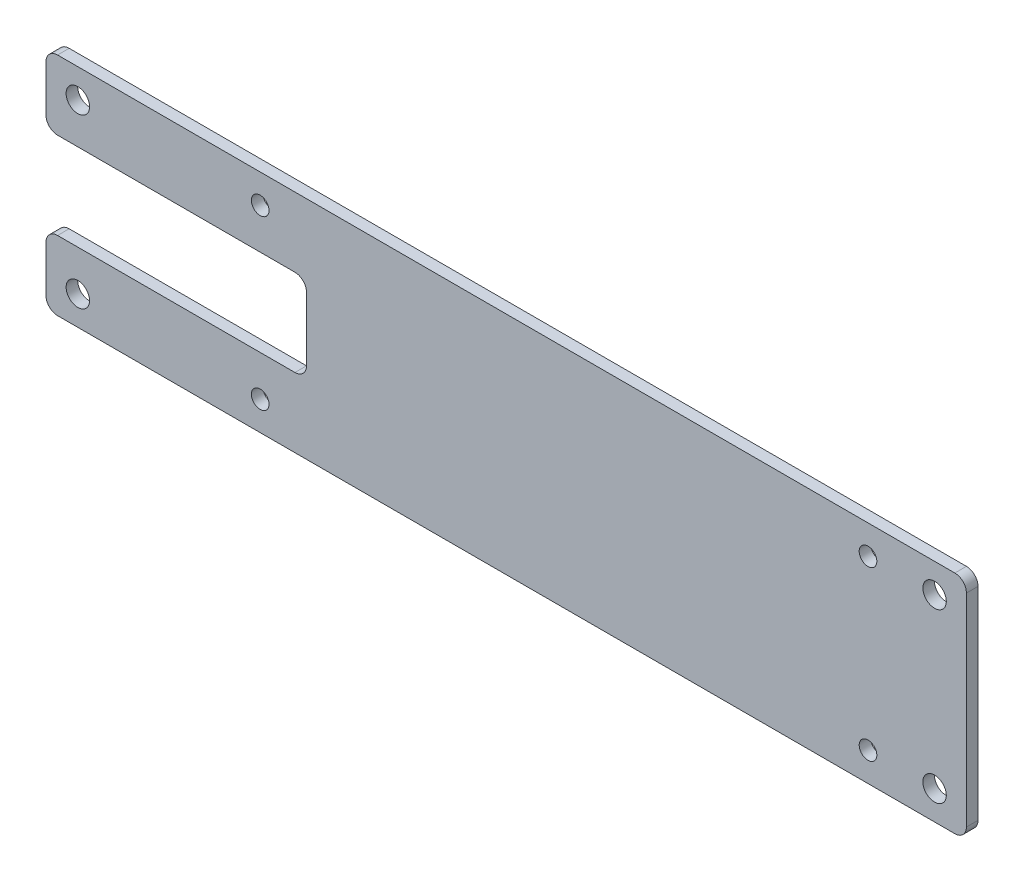
from build123d import *

# Parameters (mm, degrees)
SKETCH_1_W          = 32
SKETCH_1_H          = 39
SKETCH_1_R          = 2.025
SKETCH_1_W_2        = 115
SKETCH_1_R_2        = 1.525
SKETCH_1_W_3        = 12
EXTRUDE_1_DEPTH     = 2
SKETCH_2_W          = 19
SKETCH_2_H          = 15
SKETCH_2_W_2        = 26
CUT_EXTRUDE_1_DEPTH = 10
FILLET_1_R          = 2


with BuildPart() as part:
    # 草图1 → 凸台-拉伸1 (new body)
    with BuildSketch(Plane.XY):
        with Locations((-73.5, 0)):
            Rectangle(SKETCH_1_W, SKETCH_1_H)
        with Locations((-84, -14.5)):
            Circle(SKETCH_1_R, mode=Mode.SUBTRACT)
        with Locations((-84, 14.5)):
            Circle(SKETCH_1_R, mode=Mode.SUBTRACT)
        Rectangle(SKETCH_1_W_2, SKETCH_1_H)
        with Locations((52.5, 14.5)):
            Circle(SKETCH_1_R_2, mode=Mode.SUBTRACT)
        with Locations((52.5, -14.5)):
            Circle(SKETCH_1_R_2, mode=Mode.SUBTRACT)
        with Locations((-52.5, -14.5)):
            Circle(SKETCH_1_R_2, mode=Mode.SUBTRACT)
        with Locations((-52.5, 14.5)):
            Circle(SKETCH_1_R_2, mode=Mode.SUBTRACT)
        with Locations((63.5, 0)):
            Rectangle(SKETCH_1_W_3, SKETCH_1_H)
        with Locations((64, -14.5)):
            Circle(SKETCH_1_R, mode=Mode.SUBTRACT)
        with Locations((64, 14.5)):
            Circle(SKETCH_1_R, mode=Mode.SUBTRACT)
    extrude(amount=EXTRUDE_1_DEPTH)

    # 草图2 → 切除-拉伸1 (cut)
    with BuildSketch(Plane.XY.offset(2)):
        with Locations((-80, 0)):
            Rectangle(SKETCH_2_W, SKETCH_2_H)
        with Locations((-57.5, 0)):
            Rectangle(SKETCH_2_W_2, SKETCH_2_H)
    extrude(amount=-CUT_EXTRUDE_1_DEPTH, mode=Mode.SUBTRACT)

    # 圆角1
    fillet_1_edges = [part.edges().sort_by_distance(p)[0] for p in [
        (-89.5, 19.5, 1),
        (69.5, 19.5, 1),
        (69.5, -19.5, 1),
        (-89.5, -19.5, 1),
        (-44.5, -7.5, 1),
        (-89.5, -7.5, 1),
        (-89.5, 7.5, 1),
        (-44.5, 7.5, 1),
    ]]
    fillet(fillet_1_edges, radius=FILLET_1_R)


solid = part.part
